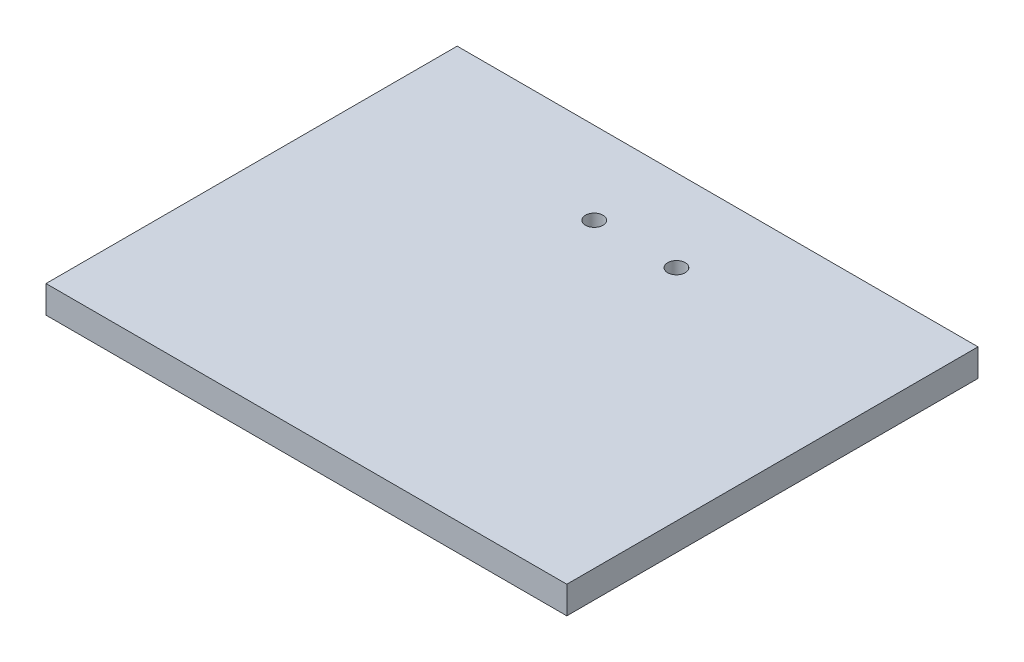
from build123d import *

# Parameters (mm, degrees)
SKETCH1_W           = 95
SKETCH1_H           = 75
BOSS_EXTRUDE1_DEPTH = 5
CUT_EXTRUDE1_REACH  = 7
SKETCH2_R           = 1.6


with BuildPart() as part:
    # Sketch1 → Boss-Extrude1 (new body)
    with BuildSketch(Plane(origin=(0, 0, 0), x_dir=(1, 0, 0), z_dir=(0, 1, 0))):
        Rectangle(SKETCH1_W, SKETCH1_H)
    extrude(amount=BOSS_EXTRUDE1_DEPTH)

    # Sketch2 → Cut-Extrude1 (cut, up to next)
    with BuildSketch(Plane(origin=(0, 0, 0), x_dir=(-1, 0, 0), z_dir=(0, -1, 0)), mode=Mode.PRIVATE) as cut_extrude1_sk1:
        with Locations((-7.5, 22.5)):
            Circle(SKETCH2_R)
    cut_extrude1_tool1 = extrude(cut_extrude1_sk1.sketch, amount=-CUT_EXTRUDE1_REACH, mode=Mode.PRIVATE) & part.part
    add(cut_extrude1_tool1.solids().sort_by_distance((7.5, 0, -22.5))[0], mode=Mode.SUBTRACT)
    # Sketch2 → Cut-Extrude1 (cut, up to next)
    with BuildSketch(Plane(origin=(0, 0, 0), x_dir=(-1, 0, 0), z_dir=(0, -1, 0)), mode=Mode.PRIVATE) as cut_extrude1_sk2:
        with Locations((7.5, 22.5)):
            Circle(SKETCH2_R)
    cut_extrude1_tool2 = extrude(cut_extrude1_sk2.sketch, amount=-CUT_EXTRUDE1_REACH, mode=Mode.PRIVATE) & part.part
    add(cut_extrude1_tool2.solids().sort_by_distance((-7.5, 0, -22.5))[0], mode=Mode.SUBTRACT)


solid = part.part
